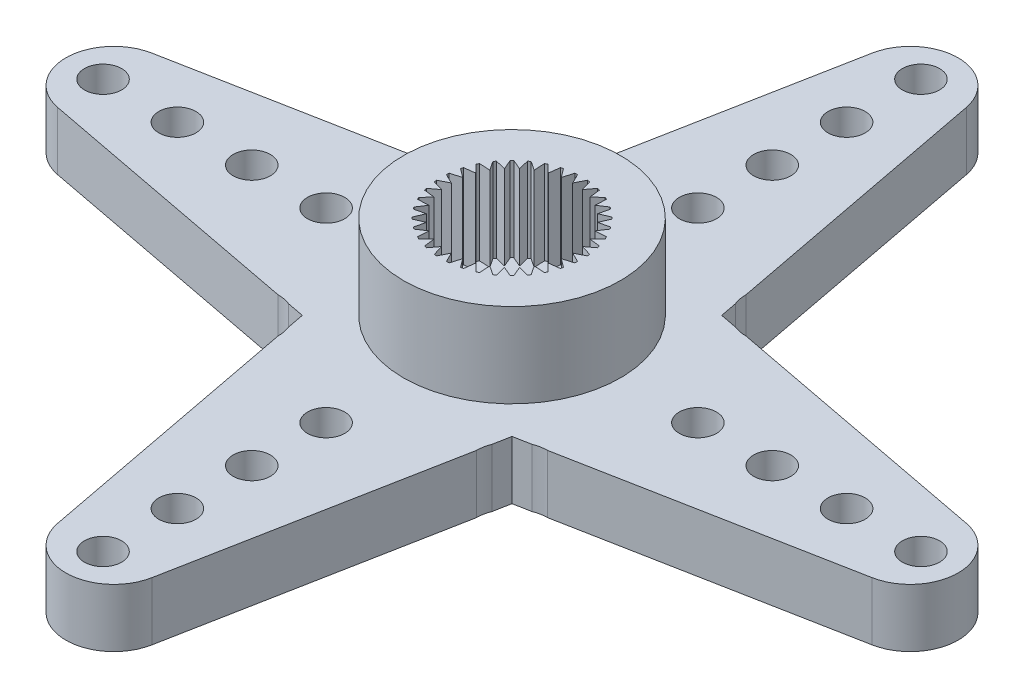
from build123d import *

# Parameters (mm, degrees)
BOSS_EXTRUDE1_DEPTH                                 = 2.35
CUT_EXTRUDE1_DEPTH                                  = 2.35
CUT_EXTRUDE2_DEPTH                                  = 2.35
CUT_EXTRUDE3_DEPTH                                  = 2.35
CUT_EXTRUDE4_DEPTH                                  = 2.35
CUT_EXTRUDE5_DEPTH                                  = 2.35
CUT_EXTRUDE6_DEPTH                                  = 2.35
CUT_EXTRUDE7_DEPTH                                  = 2.35
CUT_EXTRUDE8_DEPTH                                  = 2.35
SKETCH10_R                                          = 4.375
BOSS_EXTRUDE2_DEPTH                                 = 3.4
CUT_EXTRUDE9_DEPTH                                  = 3.4
HOLE1_D                                             = 8.8
HOLE1_DEPTH                                         = 0.3
SKETCH14_W                                          = 3.25
SKETCH14_H                                          = 0.3
F_00_CLEARANCE_HOLE1_D                              = 1.5
F_00_CLEARANCE_HOLE1_DEPTH                          = 2.35
CBORE_FOR_3_BINDING_HEAD_MACHINE_SCREW1_D           = 3
CBORE_FOR_3_BINDING_HEAD_MACHINE_SCREW1_DEPTH       = 5.75
CBORE_FOR_3_BINDING_HEAD_MACHINE_SCREW1_CBORE_D     = 5.5
CBORE_FOR_3_BINDING_HEAD_MACHINE_SCREW1_CBORE_DEPTH = 0.3


with BuildPart() as part:
    # Sketch1 → Boss-Extrude1 (new body)
    with BuildSketch(Plane(origin=(0, 2.35, 0), x_dir=(1, 0, 0), z_dir=(0, 1, 0))):
        with BuildLine():
            Line((-16.428641042, -1.9), (-4.230530925, -4.230530925))
            Line((-4.230530925, -4.230530925), (-1.9, -16.428641042))
            ThreePointArc((-1.9, -16.428641042), (0, -18), (1.9, -16.428641042))
            Line((1.9, -16.428641042), (4.230530925, -4.230530925))
            Line((4.230530925, -4.230530925), (16.428641042, -1.9))
            ThreePointArc((16.428641042, -1.9), (18, 0), (16.428641042, 1.9))
            Line((16.428641042, 1.9), (4.230530925, 4.230530925))
            Line((4.230530925, 4.230530925), (1.9, 16.428641042))
            ThreePointArc((1.9, 16.428641042), (0, 18), (-1.9, 16.428641042))
            Line((-1.9, 16.428641042), (-4.230530925, 4.230530925))
            Line((-4.230530925, 4.230530925), (-16.428641042, 1.9))
            ThreePointArc((-16.428641042, 1.9), (-18, 0), (-16.428641042, -1.9))
        make_face()
    extrude(amount=-BOSS_EXTRUDE1_DEPTH)

    # Sketch2 → Cut-Extrude1 (cut)
    with BuildSketch(Plane.XZ):
        with BuildLine():
            Line((4.101224008, 4.907329504), (4, 5.437140793))
            ThreePointArc((4, 5.437140793), (4.025532815, 5.167443601), (4.101224008, 4.907329504))
        make_face()
    extrude(amount=-CUT_EXTRUDE1_DEPTH, mode=Mode.SUBTRACT)

    # Sketch3 → Cut-Extrude2 (cut)
    with BuildSketch(Plane.XZ):
        with BuildLine():
            Line((5.437140793, 4), (4.907329504, 4.101224008))
            ThreePointArc((4.907329504, 4.101224008), (5.167443601, 4.025532815), (5.437140793, 4))
        make_face()
    extrude(amount=-CUT_EXTRUDE2_DEPTH, mode=Mode.SUBTRACT)

    # Sketch4 → Cut-Extrude3 (cut)
    with BuildSketch(Plane.XZ):
        with BuildLine():
            Line((4.907329504, -4.101224008), (5.437140793, -4))
            ThreePointArc((5.437140793, -4), (5.167443601, -4.025532815), (4.907329504, -4.101224008))
        make_face()
    extrude(amount=-CUT_EXTRUDE3_DEPTH, mode=Mode.SUBTRACT)

    # Sketch5 → Cut-Extrude4 (cut)
    with BuildSketch(Plane.XZ):
        with BuildLine():
            Line((4, -5.437140793), (4.101224008, -4.907329504))
            ThreePointArc((4.101224008, -4.907329504), (4.025532815, -5.167443601), (4, -5.437140793))
        make_face()
    extrude(amount=-CUT_EXTRUDE4_DEPTH, mode=Mode.SUBTRACT)

    # Sketch6 → Cut-Extrude5 (cut)
    with BuildSketch(Plane.XZ):
        with BuildLine():
            Line((-4.101224008, -4.907329504), (-4, -5.437140793))
            ThreePointArc((-4, -5.437140793), (-4.025532815, -5.167443601), (-4.101224008, -4.907329504))
        make_face()
    extrude(amount=-CUT_EXTRUDE5_DEPTH, mode=Mode.SUBTRACT)

    # Sketch7 → Cut-Extrude6 (cut)
    with BuildSketch(Plane.XZ):
        with BuildLine():
            Line((-5.437140793, -4), (-4.907329504, -4.101224008))
            ThreePointArc((-4.907329504, -4.101224008), (-5.167443601, -4.025532815), (-5.437140793, -4))
        make_face()
    extrude(amount=-CUT_EXTRUDE6_DEPTH, mode=Mode.SUBTRACT)

    # Sketch8 → Cut-Extrude7 (cut)
    with BuildSketch(Plane.XZ):
        with BuildLine():
            Line((-4.907329504, 4.101224008), (-5.437140793, 4))
            ThreePointArc((-5.437140793, 4), (-5.167443601, 4.025532815), (-4.907329504, 4.101224008))
        make_face()
    extrude(amount=-CUT_EXTRUDE7_DEPTH, mode=Mode.SUBTRACT)

    # Sketch9 → Cut-Extrude8 (cut)
    with BuildSketch(Plane.XZ):
        with BuildLine():
            Line((-4, 5.437140793), (-4.101224008, 4.907329504))
            ThreePointArc((-4.101224008, 4.907329504), (-4.025532815, 5.167443601), (-4, 5.437140793))
        make_face()
    extrude(amount=-CUT_EXTRUDE8_DEPTH, mode=Mode.SUBTRACT)

    # Sketch10 → Boss-Extrude2 (add)
    with BuildSketch(Plane(origin=(0, 2.35, 0), x_dir=(-1, 0, 0), z_dir=(0, 1, 0))):
        Circle(SKETCH10_R)
    extrude(amount=BOSS_EXTRUDE2_DEPTH)

    # Sketch11 → Cut-Extrude9 (cut)
    with BuildSketch(Plane(origin=(0, 5.75, 0), x_dir=(-1, 0, 0), z_dir=(0, 1, 0))):
        with BuildLine():
            Line((0.687336745, 2.765875666), (0.425438035, 2.412778995))
            Line((0.425438035, 2.412778995), (0.300099924, 2.834155965))
            ThreePointArc((0.300099924, 2.834155965), (0.248393867, 2.83915489), (0.196605286, 2.843210573))
            Line((0.196605286, 2.843210573), (0, 2.45))
            Line((0, 2.45), (-0.196605286, 2.843210573))
            ThreePointArc((-0.196605286, 2.843210573), (-0.248393867, 2.83915489), (-0.300099924, 2.834155965))
            Line((-0.300099924, 2.834155965), (-0.425438035, 2.412778995))
            Line((-0.425438035, 2.412778995), (-0.687336745, 2.765875666))
            ThreePointArc((-0.687336745, 2.765875666), (-0.737634279, 2.752888605), (-0.787686751, 2.738986963))
            Line((-0.787686751, 2.738986963), (-0.837949351, 2.302246921))
            Line((-0.837949351, 2.302246921), (-1.157183824, 2.604501026))
            ThreePointArc((-1.157183824, 2.604501026), (-1.204462046, 2.582977193), (-1.251340114, 2.560595228))
            Line((-1.251340114, 2.560595228), (-1.225, 2.121762239))
            Line((-1.225, 2.121762239), (-1.591870459, 2.363989941))
            ThreePointArc((-1.591870459, 2.363989941), (-1.634692844, 2.334583326), (-1.676972141, 2.304401102))
            Line((-1.676972141, 2.304401102), (-1.574829644, 1.876808886))
            Line((-1.574829644, 1.876808886), (-1.978188915, 2.051650218))
            ThreePointArc((-1.978188915, 2.051650218), (-2.015254326, 2.015254326), (-2.051650218, 1.978188915))
            Line((-2.051650218, 1.978188915), (-1.876808886, 1.574829644))
            Line((-1.876808886, 1.574829644), (-2.304401102, 1.676972141))
            ThreePointArc((-2.304401102, 1.676972141), (-2.334583326, 1.634692844), (-2.363989941, 1.591870459))
            Line((-2.363989941, 1.591870459), (-2.121762239, 1.225))
            Line((-2.121762239, 1.225), (-2.560595228, 1.251340114))
            ThreePointArc((-2.560595228, 1.251340114), (-2.582977193, 1.204462046), (-2.604501026, 1.157183824))
            Line((-2.604501026, 1.157183824), (-2.302246921, 0.837949351))
            Line((-2.302246921, 0.837949351), (-2.738986963, 0.787686751))
            ThreePointArc((-2.738986963, 0.787686751), (-2.752888605, 0.737634279), (-2.765875666, 0.687336745))
            Line((-2.765875666, 0.687336745), (-2.412778995, 0.425438035))
            Line((-2.412778995, 0.425438035), (-2.834155965, 0.300099924))
            ThreePointArc((-2.834155965, 0.300099924), (-2.83915489, 0.248393867), (-2.843210573, 0.196605286))
            Line((-2.843210573, 0.196605286), (-2.45, 0))
            Line((-2.45, 0), (-2.843210573, -0.196605286))
            ThreePointArc((-2.843210573, -0.196605286), (-2.83915489, -0.248393867), (-2.834155965, -0.300099924))
            Line((-2.834155965, -0.300099924), (-2.412778995, -0.425438035))
            Line((-2.412778995, -0.425438035), (-2.765875666, -0.687336745))
            ThreePointArc((-2.765875666, -0.687336745), (-2.752888605, -0.737634279), (-2.738986963, -0.787686751))
            Line((-2.738986963, -0.787686751), (-2.302246921, -0.837949351))
            Line((-2.302246921, -0.837949351), (-2.604501026, -1.157183824))
            ThreePointArc((-2.604501026, -1.157183824), (-2.582977193, -1.204462046), (-2.560595228, -1.251340114))
            Line((-2.560595228, -1.251340114), (-2.121762239, -1.225))
            Line((-2.121762239, -1.225), (-2.363989941, -1.591870459))
            ThreePointArc((-2.363989941, -1.591870459), (-2.334583326, -1.634692844), (-2.304401102, -1.676972141))
            Line((-2.304401102, -1.676972141), (-1.876808886, -1.574829644))
            Line((-1.876808886, -1.574829644), (-2.051650218, -1.978188915))
            ThreePointArc((-2.051650218, -1.978188915), (-2.015254326, -2.015254326), (-1.978188915, -2.051650218))
            Line((-1.978188915, -2.051650218), (-1.574829644, -1.876808886))
            Line((-1.574829644, -1.876808886), (-1.676972141, -2.304401102))
            ThreePointArc((-1.676972141, -2.304401102), (-1.634692844, -2.334583326), (-1.591870459, -2.363989941))
            Line((-1.591870459, -2.363989941), (-1.225, -2.121762239))
            Line((-1.225, -2.121762239), (-1.251340114, -2.560595228))
            ThreePointArc((-1.251340114, -2.560595228), (-1.204462046, -2.582977193), (-1.157183824, -2.604501026))
            Line((-1.157183824, -2.604501026), (-0.837949351, -2.302246921))
            Line((-0.837949351, -2.302246921), (-0.787686751, -2.738986963))
            ThreePointArc((-0.787686751, -2.738986963), (-0.737634279, -2.752888605), (-0.687336745, -2.765875666))
            Line((-0.687336745, -2.765875666), (-0.425438035, -2.412778995))
            Line((-0.425438035, -2.412778995), (-0.300099924, -2.834155965))
            ThreePointArc((-0.300099924, -2.834155965), (-0.248393867, -2.83915489), (-0.196605286, -2.843210573))
            Line((-0.196605286, -2.843210573), (0, -2.45))
            Line((0, -2.45), (0.196605286, -2.843210573))
            ThreePointArc((0.196605286, -2.843210573), (0.248393867, -2.83915489), (0.300099924, -2.834155965))
            Line((0.300099924, -2.834155965), (0.425438035, -2.412778995))
            Line((0.425438035, -2.412778995), (0.687336745, -2.765875666))
            ThreePointArc((0.687336745, -2.765875666), (0.737634279, -2.752888605), (0.787686751, -2.738986963))
            Line((0.787686751, -2.738986963), (0.837949351, -2.302246921))
            Line((0.837949351, -2.302246921), (1.157183824, -2.604501026))
            ThreePointArc((1.157183824, -2.604501026), (1.204462046, -2.582977193), (1.251340114, -2.560595228))
            Line((1.251340114, -2.560595228), (1.225, -2.121762239))
            Line((1.225, -2.121762239), (1.591870459, -2.363989941))
            ThreePointArc((1.591870459, -2.363989941), (1.634692844, -2.334583326), (1.676972141, -2.304401102))
            Line((1.676972141, -2.304401102), (1.574829644, -1.876808886))
            Line((1.574829644, -1.876808886), (1.978188915, -2.051650218))
            ThreePointArc((1.978188915, -2.051650218), (2.015254326, -2.015254326), (2.051650218, -1.978188915))
            Line((2.051650218, -1.978188915), (1.876808886, -1.574829644))
            Line((1.876808886, -1.574829644), (2.304401102, -1.676972141))
            ThreePointArc((2.304401102, -1.676972141), (2.334583326, -1.634692844), (2.363989941, -1.591870459))
            Line((2.363989941, -1.591870459), (2.121762239, -1.225))
            Line((2.121762239, -1.225), (2.560595228, -1.251340114))
            ThreePointArc((2.560595228, -1.251340114), (2.582977193, -1.204462046), (2.604501026, -1.157183824))
            Line((2.604501026, -1.157183824), (2.302246921, -0.837949351))
            Line((2.302246921, -0.837949351), (2.738986963, -0.787686751))
            ThreePointArc((2.738986963, -0.787686751), (2.752888605, -0.737634279), (2.765875666, -0.687336745))
            Line((2.765875666, -0.687336745), (2.412778995, -0.425438035))
            Line((2.412778995, -0.425438035), (2.834155965, -0.300099924))
            ThreePointArc((2.834155965, -0.300099924), (2.83915489, -0.248393867), (2.843210573, -0.196605286))
            Line((2.843210573, -0.196605286), (2.45, 0))
            Line((2.45, 0), (2.843210573, 0.196605286))
            ThreePointArc((2.843210573, 0.196605286), (2.83915489, 0.248393867), (2.834155965, 0.300099924))
            Line((2.834155965, 0.300099924), (2.412778995, 0.425438035))
            Line((2.412778995, 0.425438035), (2.765875666, 0.687336745))
            ThreePointArc((2.765875666, 0.687336745), (2.752888605, 0.737634279), (2.738986963, 0.787686751))
            Line((2.738986963, 0.787686751), (2.302246921, 0.837949351))
            Line((2.302246921, 0.837949351), (2.604501026, 1.157183824))
            ThreePointArc((2.604501026, 1.157183824), (2.582977193, 1.204462046), (2.560595228, 1.251340114))
            Line((2.560595228, 1.251340114), (2.121762239, 1.225))
            Line((2.121762239, 1.225), (2.363989941, 1.591870459))
            ThreePointArc((2.363989941, 1.591870459), (2.334583326, 1.634692844), (2.304401102, 1.676972141))
            Line((2.304401102, 1.676972141), (1.876808886, 1.574829644))
            Line((1.876808886, 1.574829644), (2.051650218, 1.978188915))
            ThreePointArc((2.051650218, 1.978188915), (2.015254326, 2.015254326), (1.978188915, 2.051650218))
            Line((1.978188915, 2.051650218), (1.574829644, 1.876808886))
            Line((1.574829644, 1.876808886), (1.676972141, 2.304401102))
            ThreePointArc((1.676972141, 2.304401102), (1.634692844, 2.334583326), (1.591870459, 2.363989941))
            Line((1.591870459, 2.363989941), (1.225, 2.121762239))
            Line((1.225, 2.121762239), (1.251340114, 2.560595228))
            ThreePointArc((1.251340114, 2.560595228), (1.204462046, 2.582977193), (1.157183824, 2.604501026))
            Line((1.157183824, 2.604501026), (0.837949351, 2.302246921))
            Line((0.837949351, 2.302246921), (0.787686751, 2.738986963))
            ThreePointArc((0.787686751, 2.738986963), (0.737634279, 2.752888605), (0.687336745, 2.765875666))
        make_face()
    extrude(amount=-CUT_EXTRUDE9_DEPTH, mode=Mode.SUBTRACT)

    # Hole1
    with Locations(Plane(origin=(0, 0, 0), x_dir=(-1, 0, 0), z_dir=(0, -1, 0))):
        with Locations((0, 0)):
            Hole(HOLE1_D / 2, depth=HOLE1_DEPTH)

    # Sketch14 → Revolve1 (revolve)
    with BuildSketch(Plane.XY):
        with Locations((1.625, 0.15)):
            Rectangle(SKETCH14_W, SKETCH14_H)
    revolve(axis=Axis((0, 0.3, 0), (0, -1, 0)))

    # #00 Clearance Hole1
    with Locations(Plane(origin=(0, 2.35, 0), x_dir=(1, 0, 0), z_dir=(0, 1, 0))):
        with Locations((0, -7.5), (0, -10.5), (0, -13.5), (0, -16.5), (7.5, 0), (10.5, 0), (13.5, 0), (16.5, 0), (0, 7.5), (0, 10.5), (0, 13.5), (0, 16.5), (-7.5, 0), (-10.5, 0), (-13.5, 0), (-16.5, 0)):
            Hole(F_00_CLEARANCE_HOLE1_D / 2, depth=F_00_CLEARANCE_HOLE1_DEPTH)

    # CBORE for #3 Binding Head Machine Screw1
    with Locations(Plane(origin=(0, 0, 0), x_dir=(-1, 0, 0), z_dir=(0, -1, 0))):
        with Locations((0, 0)):
            CounterBoreHole(CBORE_FOR_3_BINDING_HEAD_MACHINE_SCREW1_D / 2, CBORE_FOR_3_BINDING_HEAD_MACHINE_SCREW1_CBORE_D / 2, CBORE_FOR_3_BINDING_HEAD_MACHINE_SCREW1_CBORE_DEPTH, depth=CBORE_FOR_3_BINDING_HEAD_MACHINE_SCREW1_DEPTH)


solid = part.part
